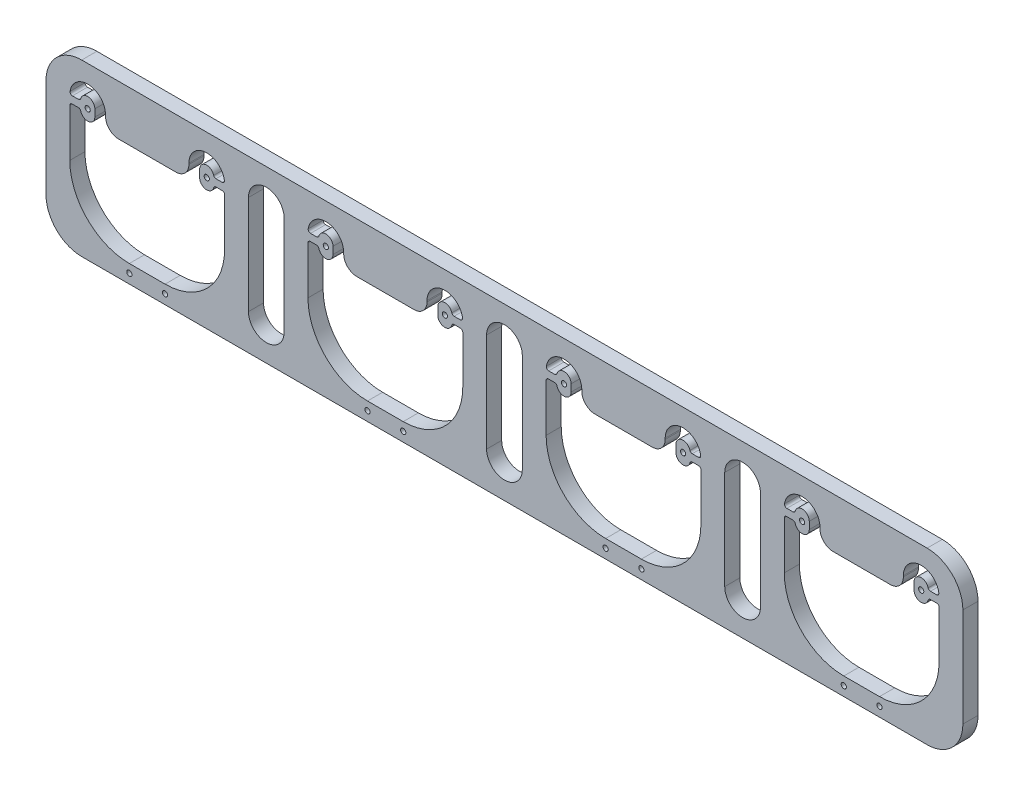
from build123d import *

# Parameters (mm, degrees)
SKETCH1_R           = 1.0922
BOSS_EXTRUDE1_DEPTH = 6.35


with BuildPart() as part:
    # Sketch1 → Boss-Extrude1 (new body)
    with BuildSketch(Plane.XY):
        with BuildLine():
            Line((-20.79604899, 49.914446368), (334.20395101, 49.914446368))
            ThreePointArc((334.20395101, 49.914446368), (344.810552728, 45.521048086), (349.20395101, 34.914446368))
            Line((349.20395101, 34.914446368), (349.20395101, -6.585553632))
            ThreePointArc((349.20395101, -6.585553632), (344.810552728, -17.19215535), (334.20395101, -21.585553632))
            Line((334.20395101, -21.585553632), (-20.79604899, -21.585553632))
            ThreePointArc((-20.79604899, -21.585553632), (-31.402650708, -17.19215535), (-35.79604899, -6.585553632))
            Line((-35.79604899, -6.585553632), (-35.79604899, 34.914446368))
            ThreePointArc((-35.79604899, 34.914446368), (-31.402650708, 45.521048086), (-20.79604899, 49.914446368))
        make_face()
        with Locations((-18.29604899, 33.414446368)):
            Circle(SKETCH1_R, mode=Mode.SUBTRACT)
        with Locations((31.70395101, 33.414446368)):
            Circle(SKETCH1_R, mode=Mode.SUBTRACT)
        with Locations((14.20395101, -17.620299938)):
            Circle(SKETCH1_R, mode=Mode.SUBTRACT)
        with Locations((-0.79604899, -17.620299938)):
            Circle(SKETCH1_R, mode=Mode.SUBTRACT)
        with Locations((81.70395101, 33.414446368)):
            Circle(SKETCH1_R, mode=Mode.SUBTRACT)
        with Locations((131.70395101, 33.414446368)):
            Circle(SKETCH1_R, mode=Mode.SUBTRACT)
        with Locations((114.20395101, -17.620299938)):
            Circle(SKETCH1_R, mode=Mode.SUBTRACT)
        with Locations((99.20395101, -17.620299938)):
            Circle(SKETCH1_R, mode=Mode.SUBTRACT)
        with Locations((181.70395101, 33.414446368)):
            Circle(SKETCH1_R, mode=Mode.SUBTRACT)
        with Locations((231.70395101, 33.414446368)):
            Circle(SKETCH1_R, mode=Mode.SUBTRACT)
        with Locations((214.20395101, -17.620299938)):
            Circle(SKETCH1_R, mode=Mode.SUBTRACT)
        with Locations((199.20395101, -17.620299938)):
            Circle(SKETCH1_R, mode=Mode.SUBTRACT)
        with Locations((281.70395101, 33.414446368)):
            Circle(SKETCH1_R, mode=Mode.SUBTRACT)
        with Locations((331.70395101, 33.414446368)):
            Circle(SKETCH1_R, mode=Mode.SUBTRACT)
        with Locations((314.20395101, -17.620299938)):
            Circle(SKETCH1_R, mode=Mode.SUBTRACT)
        with Locations((299.20395101, -17.620299938)):
            Circle(SKETCH1_R, mode=Mode.SUBTRACT)
        with BuildLine():
            Line((-25.79604899, 10.914446368), (-25.79604899, 28.914446368))
            Line((-25.79604899, 28.914446368), (-25.79604899, 30.914446368))
            ThreePointArc((-25.79604899, 30.914446368), (-25.503155771, 31.621553149), (-24.79604899, 31.914446368))
            Line((-24.79604899, 31.914446368), (-22.169032336, 31.914446368))
            ThreePointArc((-22.169032336, 31.914446368), (-21.5566599, 31.705015783), (-21.200786499, 31.164446368))
            ThreePointArc((-21.200786499, 31.164446368), (-17.918036112, 28.938357279), (-15.29604899, 31.914446368))
            Line((-15.29604899, 31.914446368), (-15.29604899, 34.914446368))
            ThreePointArc((-15.29604899, 34.914446368), (-17.918036112, 37.890535457), (-21.200786499, 35.664446368))
            ThreePointArc((-21.200786499, 35.664446368), (-21.5566599, 35.123876953), (-22.169032336, 34.914446368))
            Line((-22.169032336, 34.914446368), (-24.718665279, 34.914446368))
            ThreePointArc((-24.718665279, 34.914446368), (-25.478219804, 35.264002732), (-25.706760093, 36.068292522))
            ThreePointArc((-25.706760093, 36.068292522), (-17.717401115, 42.392090826), (-10.79604899, 34.914446368))
            Line((-10.79604899, 34.914446368), (-10.79604899, 34.414446368))
            ThreePointArc((-10.79604899, 34.414446368), (-9.185136286, 30.525359071), (-5.29604899, 28.914446368))
            Line((-5.29604899, 28.914446368), (18.70395101, 28.914446368))
            ThreePointArc((18.70395101, 28.914446368), (22.593038307, 30.525359071), (24.20395101, 34.414446368))
            Line((24.20395101, 34.414446368), (24.20395101, 34.914446368))
            ThreePointArc((24.20395101, 34.914446368), (31.125303135, 42.392090826), (39.114662113, 36.068292522))
            ThreePointArc((39.114662113, 36.068292522), (38.886121825, 35.264002732), (38.126567299, 34.914446368))
            Line((38.126567299, 34.914446368), (35.576934356, 34.914446368))
            ThreePointArc((35.576934356, 34.914446368), (34.964561921, 35.123876953), (34.60868852, 35.664446368))
            ThreePointArc((34.60868852, 35.664446368), (31.325938133, 37.890535457), (28.70395101, 34.914446368))
            Line((28.70395101, 34.914446368), (28.70395101, 31.914446368))
            ThreePointArc((28.70395101, 31.914446368), (31.325938133, 28.938357279), (34.60868852, 31.164446368))
            ThreePointArc((34.60868852, 31.164446368), (34.964561921, 31.705015783), (35.576934356, 31.914446368))
            Line((35.576934356, 31.914446368), (38.20395101, 31.914446368))
            ThreePointArc((38.20395101, 31.914446368), (38.911057791, 31.621553149), (39.20395101, 30.914446368))
            Line((39.20395101, 30.914446368), (39.20395101, 28.914446368))
            Line((39.20395101, 28.914446368), (39.20395101, 10.914446368))
            ThreePointArc((39.20395101, 10.914446368), (31.88162054, -6.763223162), (14.20395101, -14.085553632))
            Line((14.20395101, -14.085553632), (-0.79604899, -14.085553632))
            ThreePointArc((-0.79604899, -14.085553632), (-18.47371852, -6.763223162), (-25.79604899, 10.914446368))
        make_face(mode=Mode.SUBTRACT)
        with BuildLine():
            Line((74.20395101, 10.914446368), (74.20395101, 28.914446368))
            Line((74.20395101, 28.914446368), (74.20395101, 30.914446368))
            ThreePointArc((74.20395101, 30.914446368), (74.496844229, 31.621553149), (75.20395101, 31.914446368))
            Line((75.20395101, 31.914446368), (77.830967664, 31.914446368))
            ThreePointArc((77.830967664, 31.914446368), (78.4433401, 31.705015783), (78.799213501, 31.164446368))
            ThreePointArc((78.799213501, 31.164446368), (82.081963888, 28.938357279), (84.70395101, 31.914446368))
            Line((84.70395101, 31.914446368), (84.70395101, 34.914446368))
            ThreePointArc((84.70395101, 34.914446368), (82.081963888, 37.890535457), (78.799213501, 35.664446368))
            ThreePointArc((78.799213501, 35.664446368), (78.4433401, 35.123876953), (77.830967664, 34.914446368))
            Line((77.830967664, 34.914446368), (75.281334721, 34.914446368))
            ThreePointArc((75.281334721, 34.914446368), (74.521780196, 35.264002732), (74.293239907, 36.068292522))
            ThreePointArc((74.293239907, 36.068292522), (82.282598885, 42.392090826), (89.20395101, 34.914446368))
            Line((89.20395101, 34.914446368), (89.20395101, 34.414446368))
            ThreePointArc((89.20395101, 34.414446368), (90.814863714, 30.525359071), (94.70395101, 28.914446368))
            Line((94.70395101, 28.914446368), (118.70395101, 28.914446368))
            ThreePointArc((118.70395101, 28.914446368), (122.593038307, 30.525359071), (124.20395101, 34.414446368))
            Line((124.20395101, 34.414446368), (124.20395101, 34.914446368))
            ThreePointArc((124.20395101, 34.914446368), (131.125303135, 42.392090826), (139.114662113, 36.068292522))
            ThreePointArc((139.114662113, 36.068292522), (138.886121825, 35.264002732), (138.126567299, 34.914446368))
            Line((138.126567299, 34.914446368), (135.576934356, 34.914446368))
            ThreePointArc((135.576934356, 34.914446368), (134.964561921, 35.123876953), (134.60868852, 35.664446368))
            ThreePointArc((134.60868852, 35.664446368), (131.325938133, 37.890535457), (128.70395101, 34.914446368))
            Line((128.70395101, 34.914446368), (128.70395101, 31.914446368))
            ThreePointArc((128.70395101, 31.914446368), (131.325938133, 28.938357279), (134.60868852, 31.164446368))
            ThreePointArc((134.60868852, 31.164446368), (134.964561921, 31.705015783), (135.576934356, 31.914446368))
            Line((135.576934356, 31.914446368), (138.20395101, 31.914446368))
            ThreePointArc((138.20395101, 31.914446368), (138.911057791, 31.621553149), (139.20395101, 30.914446368))
            Line((139.20395101, 30.914446368), (139.20395101, 28.914446368))
            Line((139.20395101, 28.914446368), (139.20395101, 10.914446368))
            ThreePointArc((139.20395101, 10.914446368), (131.88162054, -6.763223162), (114.20395101, -14.085553632))
            Line((114.20395101, -14.085553632), (99.20395101, -14.085553632))
            ThreePointArc((99.20395101, -14.085553632), (81.52628148, -6.763223162), (74.20395101, 10.914446368))
        make_face(mode=Mode.SUBTRACT)
        with BuildLine():
            Line((174.20395101, 10.914446368), (174.20395101, 28.914446368))
            Line((174.20395101, 28.914446368), (174.20395101, 30.914446368))
            ThreePointArc((174.20395101, 30.914446368), (174.496844229, 31.621553149), (175.20395101, 31.914446368))
            Line((175.20395101, 31.914446368), (177.830967664, 31.914446368))
            ThreePointArc((177.830967664, 31.914446368), (178.4433401, 31.705015783), (178.799213501, 31.164446368))
            ThreePointArc((178.799213501, 31.164446368), (182.081963888, 28.938357279), (184.70395101, 31.914446368))
            Line((184.70395101, 31.914446368), (184.70395101, 34.914446368))
            ThreePointArc((184.70395101, 34.914446368), (182.081963888, 37.890535457), (178.799213501, 35.664446368))
            ThreePointArc((178.799213501, 35.664446368), (178.4433401, 35.123876953), (177.830967664, 34.914446368))
            Line((177.830967664, 34.914446368), (175.281334721, 34.914446368))
            ThreePointArc((175.281334721, 34.914446368), (174.521780196, 35.264002732), (174.293239907, 36.068292522))
            ThreePointArc((174.293239907, 36.068292522), (182.282598885, 42.392090826), (189.20395101, 34.914446368))
            Line((189.20395101, 34.914446368), (189.20395101, 34.414446368))
            ThreePointArc((189.20395101, 34.414446368), (190.814863714, 30.525359071), (194.70395101, 28.914446368))
            Line((194.70395101, 28.914446368), (218.70395101, 28.914446368))
            ThreePointArc((218.70395101, 28.914446368), (222.593038307, 30.525359071), (224.20395101, 34.414446368))
            Line((224.20395101, 34.414446368), (224.20395101, 34.914446368))
            ThreePointArc((224.20395101, 34.914446368), (231.125303135, 42.392090826), (239.114662113, 36.068292522))
            ThreePointArc((239.114662113, 36.068292522), (238.886121825, 35.264002732), (238.126567299, 34.914446368))
            Line((238.126567299, 34.914446368), (235.576934356, 34.914446368))
            ThreePointArc((235.576934356, 34.914446368), (234.964561921, 35.123876953), (234.60868852, 35.664446368))
            ThreePointArc((234.60868852, 35.664446368), (231.325938133, 37.890535457), (228.70395101, 34.914446368))
            Line((228.70395101, 34.914446368), (228.70395101, 31.914446368))
            ThreePointArc((228.70395101, 31.914446368), (231.325938133, 28.938357279), (234.60868852, 31.164446368))
            ThreePointArc((234.60868852, 31.164446368), (234.964561921, 31.705015783), (235.576934356, 31.914446368))
            Line((235.576934356, 31.914446368), (238.20395101, 31.914446368))
            ThreePointArc((238.20395101, 31.914446368), (238.911057791, 31.621553149), (239.20395101, 30.914446368))
            Line((239.20395101, 30.914446368), (239.20395101, 28.914446368))
            Line((239.20395101, 28.914446368), (239.20395101, 10.914446368))
            ThreePointArc((239.20395101, 10.914446368), (231.88162054, -6.763223162), (214.20395101, -14.085553632))
            Line((214.20395101, -14.085553632), (199.20395101, -14.085553632))
            ThreePointArc((199.20395101, -14.085553632), (181.52628148, -6.763223162), (174.20395101, 10.914446368))
        make_face(mode=Mode.SUBTRACT)
        with BuildLine():
            Line((274.20395101, 10.914446368), (274.20395101, 28.914446368))
            Line((274.20395101, 28.914446368), (274.20395101, 30.914446368))
            ThreePointArc((274.20395101, 30.914446368), (274.496844229, 31.621553149), (275.20395101, 31.914446368))
            Line((275.20395101, 31.914446368), (277.830967664, 31.914446368))
            ThreePointArc((277.830967664, 31.914446368), (278.4433401, 31.705015783), (278.799213501, 31.164446368))
            ThreePointArc((278.799213501, 31.164446368), (282.081963888, 28.938357279), (284.70395101, 31.914446368))
            Line((284.70395101, 31.914446368), (284.70395101, 34.914446368))
            ThreePointArc((284.70395101, 34.914446368), (282.081963888, 37.890535457), (278.799213501, 35.664446368))
            ThreePointArc((278.799213501, 35.664446368), (278.4433401, 35.123876953), (277.830967664, 34.914446368))
            Line((277.830967664, 34.914446368), (275.281334721, 34.914446368))
            ThreePointArc((275.281334721, 34.914446368), (274.521780196, 35.264002732), (274.293239907, 36.068292522))
            ThreePointArc((274.293239907, 36.068292522), (282.282598885, 42.392090826), (289.20395101, 34.914446368))
            Line((289.20395101, 34.914446368), (289.20395101, 34.414446368))
            ThreePointArc((289.20395101, 34.414446368), (290.814863714, 30.525359071), (294.70395101, 28.914446368))
            Line((294.70395101, 28.914446368), (318.70395101, 28.914446368))
            ThreePointArc((318.70395101, 28.914446368), (322.593038307, 30.525359071), (324.20395101, 34.414446368))
            Line((324.20395101, 34.414446368), (324.20395101, 34.914446368))
            ThreePointArc((324.20395101, 34.914446368), (331.125303135, 42.392090826), (339.114662113, 36.068292522))
            ThreePointArc((339.114662113, 36.068292522), (338.886121825, 35.264002732), (338.126567299, 34.914446368))
            Line((338.126567299, 34.914446368), (335.576934356, 34.914446368))
            ThreePointArc((335.576934356, 34.914446368), (334.964561921, 35.123876953), (334.60868852, 35.664446368))
            ThreePointArc((334.60868852, 35.664446368), (331.325938133, 37.890535457), (328.70395101, 34.914446368))
            Line((328.70395101, 34.914446368), (328.70395101, 31.914446368))
            ThreePointArc((328.70395101, 31.914446368), (331.325938133, 28.938357279), (334.60868852, 31.164446368))
            ThreePointArc((334.60868852, 31.164446368), (334.964561921, 31.705015783), (335.576934356, 31.914446368))
            Line((335.576934356, 31.914446368), (338.20395101, 31.914446368))
            ThreePointArc((338.20395101, 31.914446368), (338.911057791, 31.621553149), (339.20395101, 30.914446368))
            Line((339.20395101, 30.914446368), (339.20395101, 28.914446368))
            Line((339.20395101, 28.914446368), (339.20395101, 10.914446368))
            ThreePointArc((339.20395101, 10.914446368), (331.88162054, -6.763223162), (314.20395101, -14.085553632))
            Line((314.20395101, -14.085553632), (299.20395101, -14.085553632))
            ThreePointArc((299.20395101, -14.085553632), (281.52628148, -6.763223162), (274.20395101, 10.914446368))
        make_face(mode=Mode.SUBTRACT)
        with BuildLine():
            Line((49.20395101, 34.914446368), (49.20395101, -6.585553632))
            ThreePointArc((49.20395101, -6.585553632), (56.70395101, -14.085553632), (64.20395101, -6.585553632))
            Line((64.20395101, -6.585553632), (64.20395101, 34.914446368))
            ThreePointArc((64.20395101, 34.914446368), (56.70395101, 42.414446368), (49.20395101, 34.914446368))
        make_face(mode=Mode.SUBTRACT)
        with BuildLine():
            Line((164.20395101, -6.585553632), (164.20395101, 34.914446368))
            ThreePointArc((164.20395101, 34.914446368), (156.70395101, 42.414446368), (149.20395101, 34.914446368))
            Line((149.20395101, 34.914446368), (149.20395101, -6.585553632))
            ThreePointArc((149.20395101, -6.585553632), (156.70395101, -14.085553632), (164.20395101, -6.585553632))
        make_face(mode=Mode.SUBTRACT)
        with BuildLine():
            Line((264.20395101, -6.585553632), (264.20395101, 34.914446368))
            ThreePointArc((264.20395101, 34.914446368), (256.70395101, 42.414446368), (249.20395101, 34.914446368))
            Line((249.20395101, 34.914446368), (249.20395101, -6.585553632))
            ThreePointArc((249.20395101, -6.585553632), (256.70395101, -14.085553632), (264.20395101, -6.585553632))
        make_face(mode=Mode.SUBTRACT)
    extrude(amount=BOSS_EXTRUDE1_DEPTH)


solid = part.part
